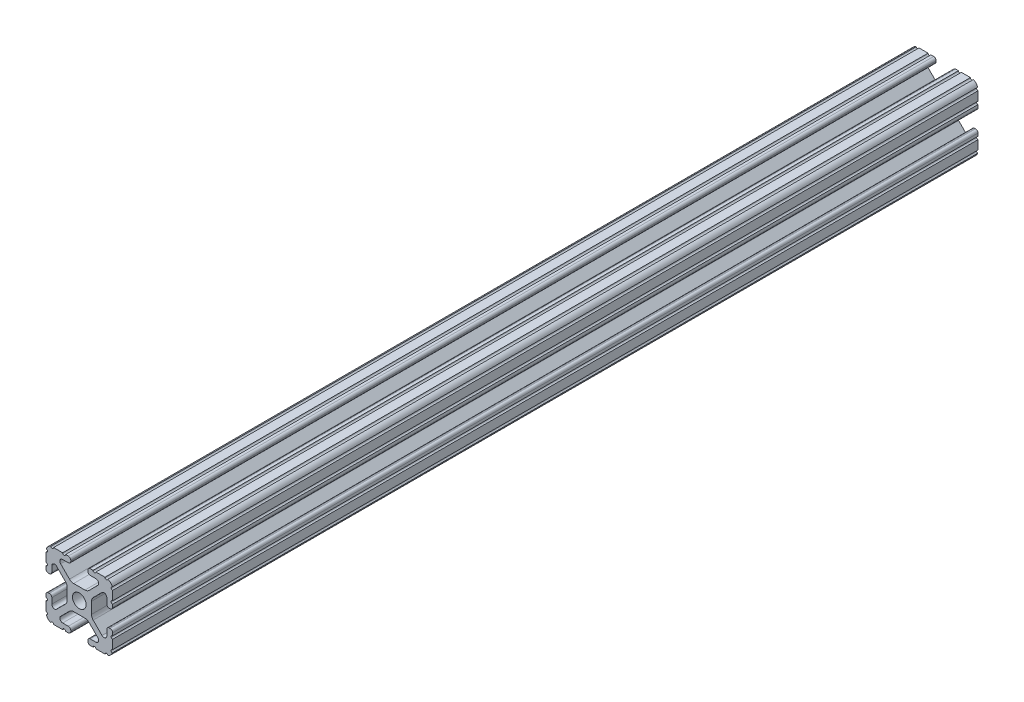
from build123d import *

# Parameters (mm, degrees)
BOSS_EXTRUDE1_DEPTH     = 165.1
SKETCH5_R               = 0.55245
CUT_EXTRUDE1_DEPTH      = 166.1
CUT_EXTRUDE1_DEPTH_BACK = 166.1


with BuildPart() as part:
    # Sketch4 → Boss-Extrude1 (new body, symmetric)
    with BuildSketch(Plane.XY):
        with BuildLine():
            Line((4.190365, -12.7), (10.11729625, -12.7))
            ThreePointArc((10.11729625, -12.7), (11.943543585, -11.943543585), (12.7, -10.11729625))
            Line((12.7, -10.11729625), (12.7, -4.190365))
            ThreePointArc((12.7, -4.190365), (12.42492494, -3.52627506), (11.760835, -3.2512))
            Line((11.760835, -3.2512), (11.429365, -3.2512))
            ThreePointArc((11.429365, -3.2512), (10.76527506, -3.52627506), (10.4902, -4.190365))
            Line((10.4902, -4.190365), (10.4902, -6.348478019))
            ThreePointArc((10.4902, -6.348478019), (9.830707141, -7.335478831), (8.666460301, -7.103895736))
            Line((8.666460301, -7.103895736), (5.299899128, -3.737334563))
            ThreePointArc((5.299899128, -3.737334563), (4.817571085, -3.015479634), (4.6482, -2.16399369))
            Line((4.6482, -2.16399369), (4.6482, 0))
            Line((4.6482, 0), (2.6035, 0))
            ThreePointArc((2.6035, 0), (1.840952505, -1.840952505), (0, -2.6035))
            Line((0, -2.6035), (0, -4.6482))
            Line((0, -4.6482), (2.16399369, -4.6482))
            ThreePointArc((2.16399369, -4.6482), (3.015479634, -4.817571085), (3.737334563, -5.299899128))
            Line((3.737334563, -5.299899128), (7.103895736, -8.666460301))
            ThreePointArc((7.103895736, -8.666460301), (7.335478831, -9.830707141), (6.348478019, -10.4902))
            Line((6.348478019, -10.4902), (4.190365, -10.4902))
            ThreePointArc((4.190365, -10.4902), (3.52627506, -10.76527506), (3.2512, -11.429365))
            Line((3.2512, -11.429365), (3.2512, -11.760835))
            ThreePointArc((3.2512, -11.760835), (3.52627506, -12.42492494), (4.190365, -12.7))
        make_face()
    extrude(amount=BOSS_EXTRUDE1_DEPTH, both=True)

    # Sketch5 → Cut-Extrude1 (cut, two sides)
    with BuildSketch(Plane.XY) as cut_extrude1_sk:
        with Locations((10.356153152, -12.7)):
            Circle(SKETCH5_R)
        with Locations((5.796028019, -12.7)):
            Circle(SKETCH5_R)
        with Locations((12.7, -10.356153152)):
            Circle(SKETCH5_R)
        with Locations((12.7, -5.796028019)):
            Circle(SKETCH5_R)
    extrude(amount=CUT_EXTRUDE1_DEPTH, mode=Mode.SUBTRACT)
    extrude(cut_extrude1_sk.sketch, amount=-CUT_EXTRUDE1_DEPTH_BACK, mode=Mode.SUBTRACT)

    # Mirror1: part across plane


with BuildPart() as part_1:
    add(part.part)
    add(part.part.mirror(Plane(origin=(0, 0, 0), x_dir=(0, 0, 1), z_dir=(1, 0, 0))))

    # Mirror2: part across plane


with BuildPart() as part_2:
    add(part_1.part)
    add(part_1.part.mirror(Plane.ZX))


solid = part_2.part
